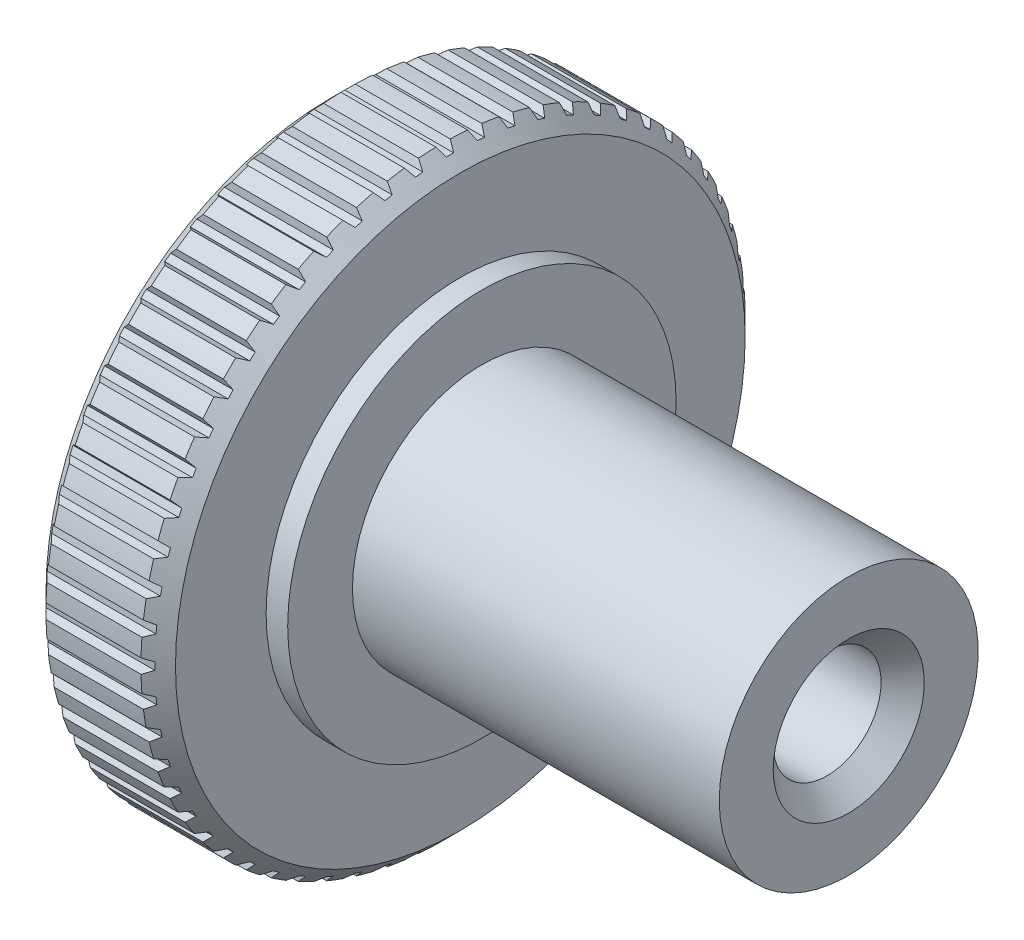
from build123d import *

# Parameters (mm, degrees)
CHAMFER1_SIZE      = 0.4
CUT_EXTRUDE1_DEPTH = 3
CIRPATTERN1_COUNT  = 60
SKETCH6_R          = 1.25
CUT_EXTRUDE2_DEPTH = 13
CHAMFER2_SIZE      = 0.5


with BuildPart() as part:
    # Sketch1 → Revolve1 (revolve)
    with BuildSketch(Plane.XY):
        Polygon((12, 0), (12, 3), (3.5, 3), (3.5, 4.5), (3, 4.5), (3, 7), (0, 7), (0, 0), align=None)
    revolve(axis=Axis((-16.113670608, 0, 0), (1, 0, 0)))

    # Chamfer1
    chamfer1_edges = [part.edges().sort_by_distance(p)[0] for p in [
        (0, -7, 0),
        (3, -7, 0),
    ]]
    chamfer(chamfer1_edges, length=CHAMFER1_SIZE)

    # Sketch5 → Cut-Extrude1 (cut)
    with BuildSketch(Plane.ZY):
        with BuildLine():
            Line((-0.085000968, 6.839), (0.085000968, 6.839))
            Line((0.085000968, 6.839), (0.165, 6.998055087))
            ThreePointArc((0.165, 6.998055087), (0, 7), (-0.165, 6.998055087))
            Line((-0.165, 6.998055087), (-0.085000968, 6.839))
        make_face()
    cut_extrude1 = extrude(amount=-CUT_EXTRUDE1_DEPTH, mode=Mode.SUBTRACT)

    # CirPattern1: Cut-Extrude1 ×60 about axis
    cirpattern1_axis = Axis((0, 0, 0), (1, 0, 0))
    for i in range(1, CIRPATTERN1_COUNT):
        add(cut_extrude1.rotate(cirpattern1_axis, i * 360 / CIRPATTERN1_COUNT), mode=Mode.SUBTRACT)

    # Sketch6 → Cut-Extrude2 (cut, through all)
    with BuildSketch(Plane(origin=(12, 0, 0), x_dir=(0, 0, -1), z_dir=(1, 0, 0))):
        Circle(SKETCH6_R)
    extrude(amount=-CUT_EXTRUDE2_DEPTH, mode=Mode.SUBTRACT)

    # Chamfer2
    chamfer2_edges = [part.edges().sort_by_distance(p)[0] for p in [
        (0, 0, 1.25),
        (12, 0, 1.25),
    ]]
    chamfer(chamfer2_edges, length=CHAMFER2_SIZE)


solid = part.part
